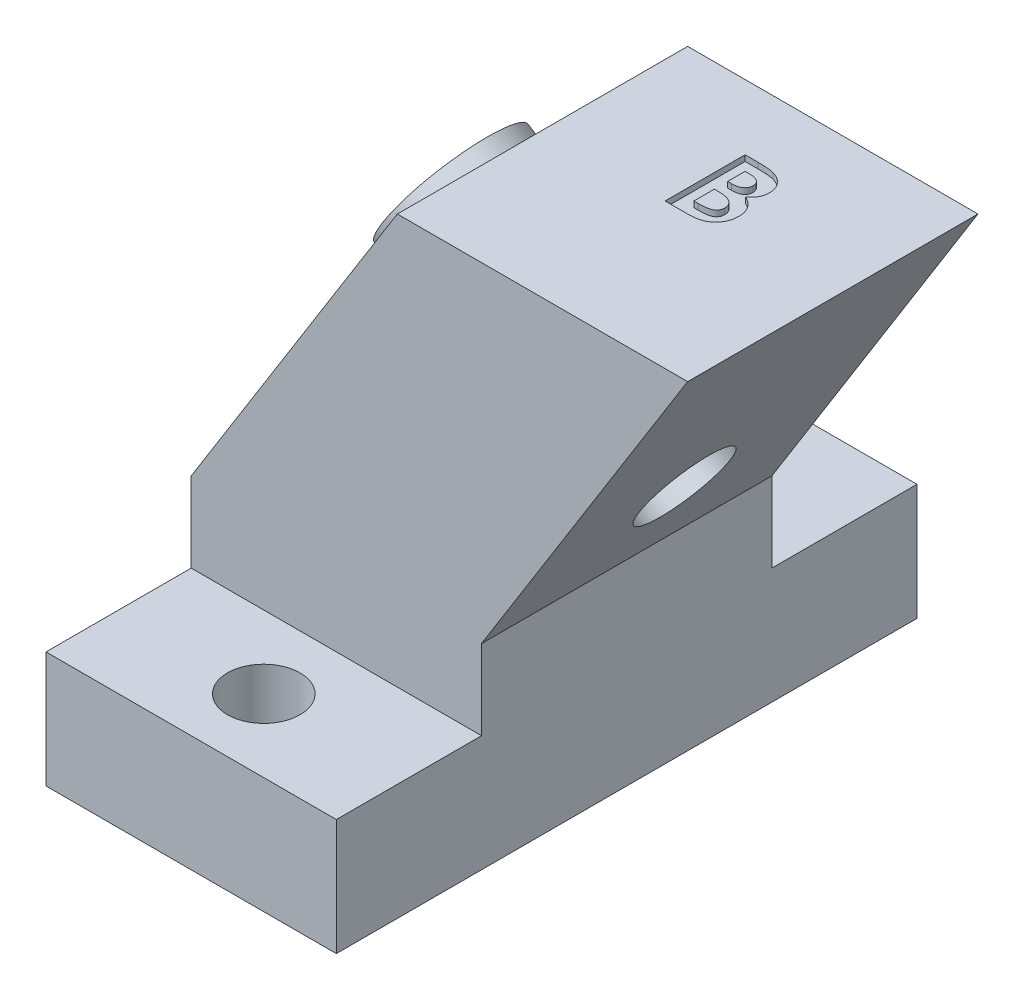
from build123d import *

# Parameters (mm, degrees)
BOSS_EXTRUDE3_DEPTH = 12.7
SKETCH8_R           = 2
CUT_EXTRUDE5_DEPTH  = 12.7
CUT_EXTRUDE7_DEPTH  = 12.7
SKETCH10_W          = 12.7
SKETCH10_H          = 5.08
BOSS_EXTRUDE4_DEPTH = 6.35
SKETCH11_R          = 1.5875
CUT_EXTRUDE8_DEPTH  = 12.7
SKETCH13_R          = 3
SKETCH13_R_2        = 2
BOSS_EXTRUDE5_DEPTH = 1.27
CUT_EXTRUDE10_DEPTH = 0.254


with BuildPart() as part:
    # Sketch7 → Boss-Extrude3 (new body)
    with BuildSketch(Plane.XY):
        Polygon((0, 8.571363245), (12.192, 28.082641823), (24.892, 28.082641823), (12.7, 8.571363245), (12.7, 0), (0, 0), align=None)
    extrude(amount=BOSS_EXTRUDE3_DEPTH)

    # Sketch8 → Cut-Extrude5 (cut)
    with BuildSketch(Plane(origin=(-3.851945127, 2.406962455, 0), x_dir=(0, 0, 1), z_dir=(-0.848048096, 0.529919264, 0))):
        with Locations((6.35, 18.772567442)):
            Circle(SKETCH8_R)
    extrude(amount=-CUT_EXTRUDE5_DEPTH, mode=Mode.SUBTRACT)

    # Sketch9 → Cut-Extrude7 (cut)
    with BuildSketch(Plane.XY.offset(12.7)):
        Polygon((21.717663692, 23.002641823), (9.017663692, 23.002641823), (12.192, 28.082641823), (24.892, 28.082641823), align=None)
    extrude(amount=-CUT_EXTRUDE7_DEPTH, mode=Mode.SUBTRACT)

    # Sketch10 → Boss-Extrude4 (add)
    with BuildSketch(Plane.XY.offset(12.7)):
        with Locations((6.35, 2.54)):
            Rectangle(SKETCH10_W, SKETCH10_H)
    boss_extrude4 = extrude(amount=BOSS_EXTRUDE4_DEPTH)

    # Sketch11 → Cut-Extrude8 (cut)
    with BuildSketch(Plane(origin=(0, 5.08, 0), x_dir=(1, 0, 0), z_dir=(0, 1, 0))):
        with Locations((6.35, -15.875)):
            Circle(SKETCH11_R)
    cut_extrude8 = extrude(amount=-CUT_EXTRUDE8_DEPTH, mode=Mode.SUBTRACT)

    # Mirror2: Boss-Extrude4, Cut-Extrude8 across plane
    add(boss_extrude4.mirror(Plane.XY.offset(6.35)))
    add(cut_extrude8.mirror(Plane.XY.offset(6.35)), mode=Mode.SUBTRACT)

    # Sketch13 → Boss-Extrude5 (add)
    with BuildSketch(Plane(origin=(-3.851945127, 2.406962455, 0), x_dir=(0, 0, 1), z_dir=(-0.848048096, 0.529919264, 0))):
        with Locations((6.35, 18.772567442)):
            Circle(SKETCH13_R)
        with Locations((6.35, 18.772567442)):
            Circle(SKETCH13_R_2, mode=Mode.SUBTRACT)
    extrude(amount=BOSS_EXTRUDE5_DEPTH)

    # Sketch17 → Cut-Extrude10 (cut)
    with BuildSketch(Plane(origin=(0, 23.002641823, 0), x_dir=(1, 0, 0), z_dir=(0, 1, 0))):
        with BuildLine():
            Line((14.380484205, -6.35), (14.380484205, -2.85))
            Line((14.380484205, -2.85), (14.941381641, -2.85))
            add(Edge.make_bspline(
                [(14.941381641, -2.85), (14.980647969, -2.849995519), (15.056627568, -2.849986848), (15.166246302, -2.853836298), (15.267908419, -2.858815992), (15.361290393, -2.864387113), (15.446551165, -2.873987267), (15.523561083, -2.88410478), (15.592474012, -2.896305878), (15.635079132, -2.907250641), (15.655123628, -2.91239984)],
                knots=[0, 0, 0, 0, 0.000117791, 0.000227922, 0.000329003, 0.000423165, 0.000508489, 0.000586326, 0.000656186, 0.000718254, 0.000718254, 0.000718254, 0.000718254], degree=3))
            add(Edge.make_bspline(
                [(15.655123628, -2.91239984), (15.681444087, -2.919662877), (15.733093276, -2.933915288), (15.807071397, -2.962698647), (15.877249964, -2.994693392), (15.943543291, -3.031193412), (16.005544311, -3.072639364), (16.063017398, -3.119360176), (16.117202106, -3.169480477), (16.166174458, -3.224397106), (16.210437395, -3.282426696), (16.248893952, -3.343554044), (16.28230777, -3.406844471), (16.309047578, -3.473094446), (16.32919552, -3.54199887), (16.343931641, -3.61326351), (16.353482643, -3.687113865), (16.354385087, -3.737356675), (16.354843179, -3.762860577)],
                knots=[0, 0, 0, 0, 8.1863e-05, 0.000160642, 0.000237816, 0.000313134, 0.000387417, 0.000461218, 0.000535129, 0.000608609, 0.000681668, 0.000753832, 0.000825019, 0.000896106, 0.000967761, 0.001040089, 0.001114269, 0.001190743, 0.001190743, 0.001190743, 0.001190743], degree=3))
            add(Edge.make_bspline(
                [(16.354843179, -3.762860577), (16.353645404, -3.795626396), (16.351287729, -3.860121885), (16.336226745, -3.954854089), (16.307985053, -4.044389639), (16.271031486, -4.130378639), (16.220786188, -4.212500352), (16.156984378, -4.290715729), (16.080659434, -4.367433141), (16.022113989, -4.413420054), (15.99166209, -4.437339744)],
                knots=[0, 0, 0, 0, 9.8317e-05, 0.000193525, 0.000286672, 0.000379289, 0.00047368, 0.000574417, 0.000681503, 0.000797579, 0.000797579, 0.000797579, 0.000797579], degree=3))
            add(Edge.make_bspline(
                [(15.99166209, -4.437339744), (16.016338848, -4.449937015), (16.064723145, -4.474636779), (16.133414631, -4.515235817), (16.197015449, -4.558418043), (16.255810766, -4.603314613), (16.308567282, -4.651828759), (16.357463403, -4.701165027), (16.400086847, -4.754150182), (16.438202016, -4.808895731), (16.471331101, -4.866194396), (16.500182881, -4.925949414), (16.524552945, -4.988364919), (16.545190145, -5.053123267), (16.560581374, -5.120447198), (16.570616783, -5.190360788), (16.57830052, -5.262625597), (16.578898242, -5.311850581), (16.579202154, -5.336879006)],
                knots=[0, 0, 0, 0, 8.3106e-05, 0.000162948, 0.000239177, 0.000313644, 0.000384624, 0.000454039, 0.000521819, 0.000588334, 0.000653992, 0.000720158, 0.00078721, 0.000854842, 0.000923894, 0.000994098, 0.001066653, 0.001141702, 0.001141702, 0.001141702, 0.001141702], degree=3))
            add(Edge.make_bspline(
                [(16.579202154, -5.336879006), (16.577229969, -5.384681869), (16.573337872, -5.479020625), (16.544880751, -5.617531587), (16.495545146, -5.748852541), (16.429297601, -5.872461563), (16.34766788, -5.984780374), (16.25381711, -6.083170677), (16.148690152, -6.166455884), (16.051697827, -6.222666938), (15.967807104, -6.260389811), (15.898321986, -6.28371247), (15.823696442, -6.305318547), (15.742563511, -6.32049078), (15.656394023, -6.334378075), (15.564347819, -6.34295238), (15.466596934, -6.348762974), (15.3994574, -6.349579322), (15.364859205, -6.35)],
                knots=[0, 0, 0, 0, 0.000143365, 0.000282931, 0.000422024, 0.000562867, 0.000702406, 0.000837288, 0.000969562, 0.001103403, 0.001172455, 0.001245183, 0.001323096, 0.001405322, 0.001492583, 0.001584881, 0.001682498, 0.001786285, 0.001786285, 0.001786285, 0.001786285], degree=3))
            Line((15.364859205, -6.35), (14.380484205, -6.35))
        make_face()
        with BuildLine():
            Line((15.008689333, -3.478205128), (15.008689333, -4.241025641))
            Line((15.008689333, -4.241025641), (15.175556321, -4.241025641))
            add(Edge.make_bspline(
                [(15.175556321, -4.241025641), (15.198235043, -4.240827874), (15.242014945, -4.240446097), (15.305250369, -4.235528937), (15.364049102, -4.227139958), (15.418188132, -4.215435223), (15.468171784, -4.200571914), (15.513680747, -4.182688154), (15.554514928, -4.160868022), (15.601954802, -4.128365973), (15.65210217, -4.080537752), (15.696246334, -4.011439977), (15.722246952, -3.9319778), (15.725142719, -3.875934919), (15.726638051, -3.846995192)],
                knots=[0, 0, 0, 0, 6.8023e-05, 0.000131315, 0.000190113, 0.000246084, 0.000297324, 0.000346407, 0.000392516, 0.000435884, 0.000518691, 0.000598437, 0.000679585, 0.000766233, 0.000766233, 0.000766233, 0.000766233], degree=3))
            add(Edge.make_bspline(
                [(15.726638051, -3.846995192), (15.725441512, -3.81988833), (15.723128051, -3.7674783), (15.696948772, -3.693889951), (15.656287176, -3.628675613), (15.608280446, -3.584041731), (15.563072782, -3.553558106), (15.524363206, -3.533485938), (15.481876539, -3.515517537), (15.434790286, -3.50177846), (15.383373334, -3.491469141), (15.327875445, -3.48389818), (15.268200865, -3.478745062), (15.226983506, -3.478388967), (15.205704558, -3.478205128)],
                knots=[0, 0, 0, 0, 8.0997e-05, 0.000156604, 0.000231296, 0.000309653, 0.000351072, 0.000394666, 0.000440239, 0.000489262, 0.000541514, 0.000597437, 0.000657234, 0.000721051, 0.000721051, 0.000721051, 0.000721051], degree=3))
            Line((15.205704558, -3.478205128), (15.008689333, -3.478205128))
        make_face(mode=Mode.SUBTRACT)
        with BuildLine():
            Line((15.008689333, -4.824358974), (15.008689333, -5.721794872))
            Line((15.008689333, -5.721794872), (15.189578756, -5.721794872))
            add(Edge.make_bspline(
                [(15.189578756, -5.721794872), (15.225340826, -5.721590564), (15.294097866, -5.721197758), (15.392592205, -5.716451722), (15.482148183, -5.707897829), (15.56252851, -5.697218983), (15.633856304, -5.682750816), (15.695890459, -5.664356397), (15.749481695, -5.644119331), (15.794308675, -5.619124153), (15.830929749, -5.590035963), (15.863976429, -5.560307135), (15.890920633, -5.526012123), (15.91223939, -5.488623117), (15.930690736, -5.449068886), (15.941819286, -5.405804853), (15.950292172, -5.36011326), (15.950758458, -5.328509373), (15.950997026, -5.312339744)],
                knots=[0, 0, 0, 0, 0.000107281, 0.000206261, 0.0002957, 0.000377105, 0.000449433, 0.000513769, 0.000571055, 0.000620973, 0.00066697, 0.000711118, 0.000754041, 0.00079709, 0.000840088, 0.000884486, 0.000930707, 0.00097913, 0.00097913, 0.00097913, 0.00097913], degree=3))
            add(Edge.make_bspline(
                [(15.950997026, -5.312339744), (15.950470915, -5.293849518), (15.949446194, -5.257835532), (15.941077284, -5.205197249), (15.925868241, -5.156055919), (15.906711709, -5.109154932), (15.880054377, -5.066173507), (15.848373048, -5.02562422), (15.810093916, -4.988880195), (15.767046798, -4.953719015), (15.716836597, -4.922933498), (15.659439756, -4.896221608), (15.594544464, -4.873912821), (15.5219497, -4.856150551), (15.441973715, -4.841075958), (15.354032772, -4.832074761), (15.258859273, -4.825380176), (15.19286442, -4.82470711), (15.158729397, -4.824358974)],
                knots=[0, 0, 0, 0, 5.546e-05, 0.00010802, 0.00015926, 0.000209526, 0.000259547, 0.000310464, 0.000363513, 0.000418371, 0.000476935, 0.000539665, 0.000607959, 0.000682439, 0.000763712, 0.0008519, 0.000947461, 0.001049847, 0.001049847, 0.001049847, 0.001049847], degree=3))
            Line((15.158729397, -4.824358974), (15.008689333, -4.824358974))
        make_face(mode=Mode.SUBTRACT)
    extrude(amount=-CUT_EXTRUDE10_DEPTH, mode=Mode.SUBTRACT)


solid = part.part
